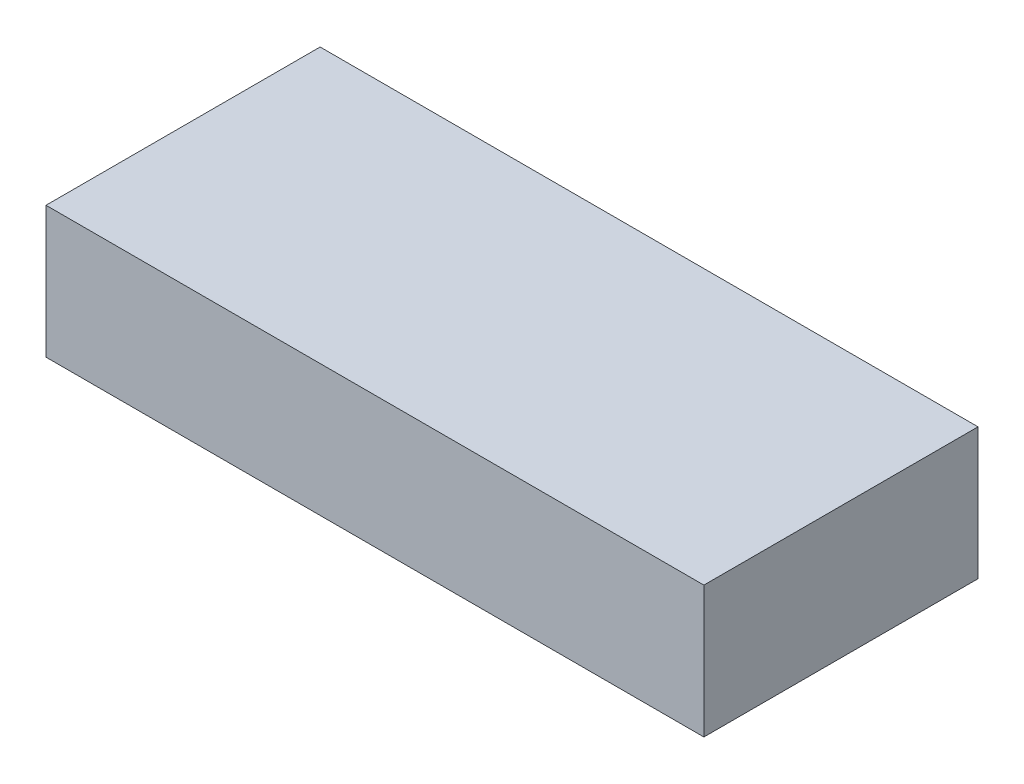
from build123d import *

# Parameters (mm, degrees)
SKETCH_1_W      = 480
SKETCH_1_H      = 96
EXTRUDE_1_DEPTH = 200


with BuildPart() as part:
    # Эскиз1 → Бобышка-Вытянуть1 (new body)
    with BuildSketch(Plane.XY):
        Rectangle(SKETCH_1_W, SKETCH_1_H)
    extrude(amount=EXTRUDE_1_DEPTH)


solid = part.part
